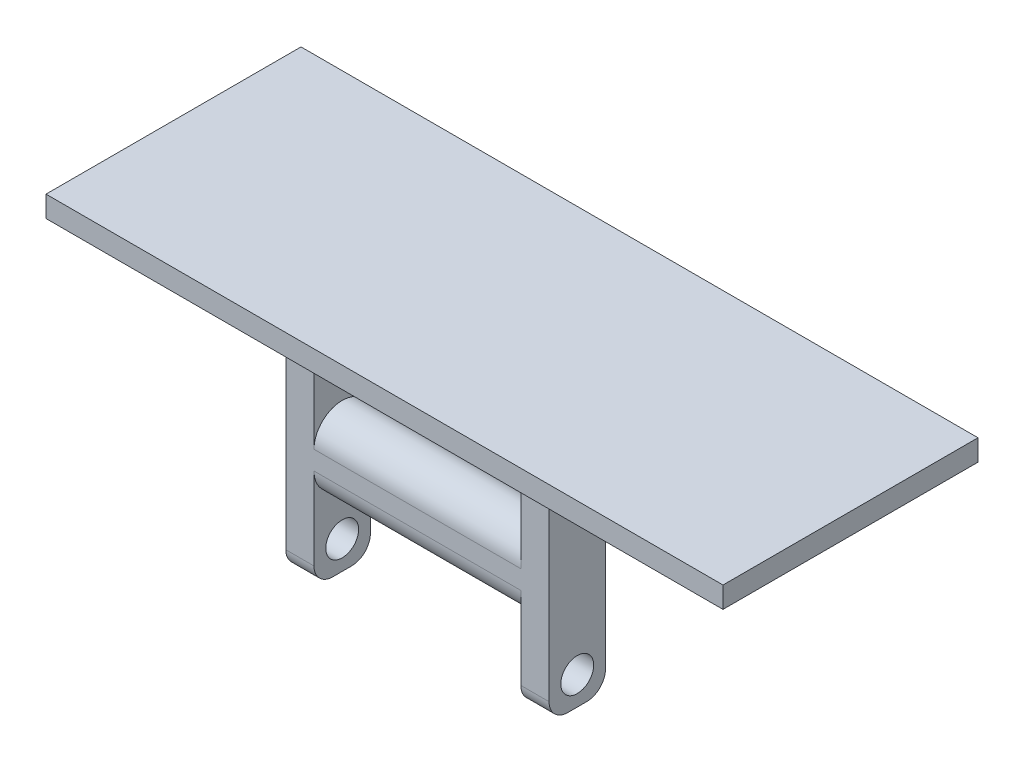
from build123d import *

# Parameters (mm, degrees)
SALIENTE_EXTRUIR1_DEPTH      = 14
CROQUIS3_W                   = 6
CROQUIS3_H                   = 23.5
CROQUIS3_R                   = 1.75
SALIENTE_EXTRUIR2_DEPTH      = 3
REDONDEO1_R                  = 2
REDONDEO1_OF_SIMETR_A1_R     = 2
CROQUIS6_W                   = 72
CROQUIS6_H                   = 27.119895789
SALIENTE_EXTRUIR5_DEPTH      = 2
SALIENTE_EXTRUIR5_DEPTH_BACK = 0.25


with BuildPart() as part:
    # Croquis2 → Saliente-Extruir1 (new body)
    with BuildSketch(Plane(origin=(0, 0, 0), x_dir=(0, 0, -1), z_dir=(1, 0, 0))):
        with BuildLine():
            Line((-3, -1), (-3, 1))
            ThreePointArc((-3, 1), (0, 4), (3, 1))
            Line((3, 1), (3, -1))
            ThreePointArc((3, -1), (0, -4), (-3, -1))
        make_face()
    saliente_extruir1 = extrude(amount=SALIENTE_EXTRUIR1_DEPTH)

    # Croquis3 → Saliente-Extruir2 (add)
    with BuildSketch(Plane(origin=(14, 0, 0), x_dir=(0, 0, -1), z_dir=(1, 0, 0))):
        Rectangle(CROQUIS3_W, CROQUIS3_H)
        with Locations((0, 8.75)):
            Circle(CROQUIS3_R, mode=Mode.SUBTRACT)
        with Locations((0, -8.75)):
            Circle(CROQUIS3_R, mode=Mode.SUBTRACT)
    saliente_extruir2 = extrude(amount=-SALIENTE_EXTRUIR2_DEPTH)

    # Redondeo1
    redondeo1_edges = [part.edges().sort_by_distance(p)[0] for p in [
        (12.5, -11.75, -3),
        (12.5, -11.75, 3),
    ]]
    fillet(redondeo1_edges, radius=REDONDEO1_R)

    # Simetría1: Saliente-Extruir1, Saliente-Extruir2 across plane
    add(saliente_extruir1.mirror(Plane(origin=(0, 0, 0), x_dir=(0, 0, 1), z_dir=(1, 0, 0))))
    add(saliente_extruir2.mirror(Plane(origin=(0, 0, 0), x_dir=(0, 0, 1), z_dir=(1, 0, 0))))

    # Redondeo1 of Simetría1
    redondeo1_of_simetr_a1_edges = [part.edges().sort_by_distance(p)[0] for p in [
        (-12.5, -11.75, -3),
        (-12.5, -11.75, 3),
    ]]
    fillet(redondeo1_of_simetr_a1_edges, radius=REDONDEO1_OF_SIMETR_A1_R)

    # Croquis6 → Saliente-Extruir5 (add, two sides)
    with BuildSketch(Plane(origin=(0, 11.75, 0), x_dir=(1, 0, 0), z_dir=(0, 1, 0))) as saliente_extruir5_sk:
        with Locations((0, 7.059947895)):
            Rectangle(CROQUIS6_W, CROQUIS6_H)
    extrude(amount=SALIENTE_EXTRUIR5_DEPTH)
    extrude(saliente_extruir5_sk.sketch, amount=-SALIENTE_EXTRUIR5_DEPTH_BACK)


solid = part.part
